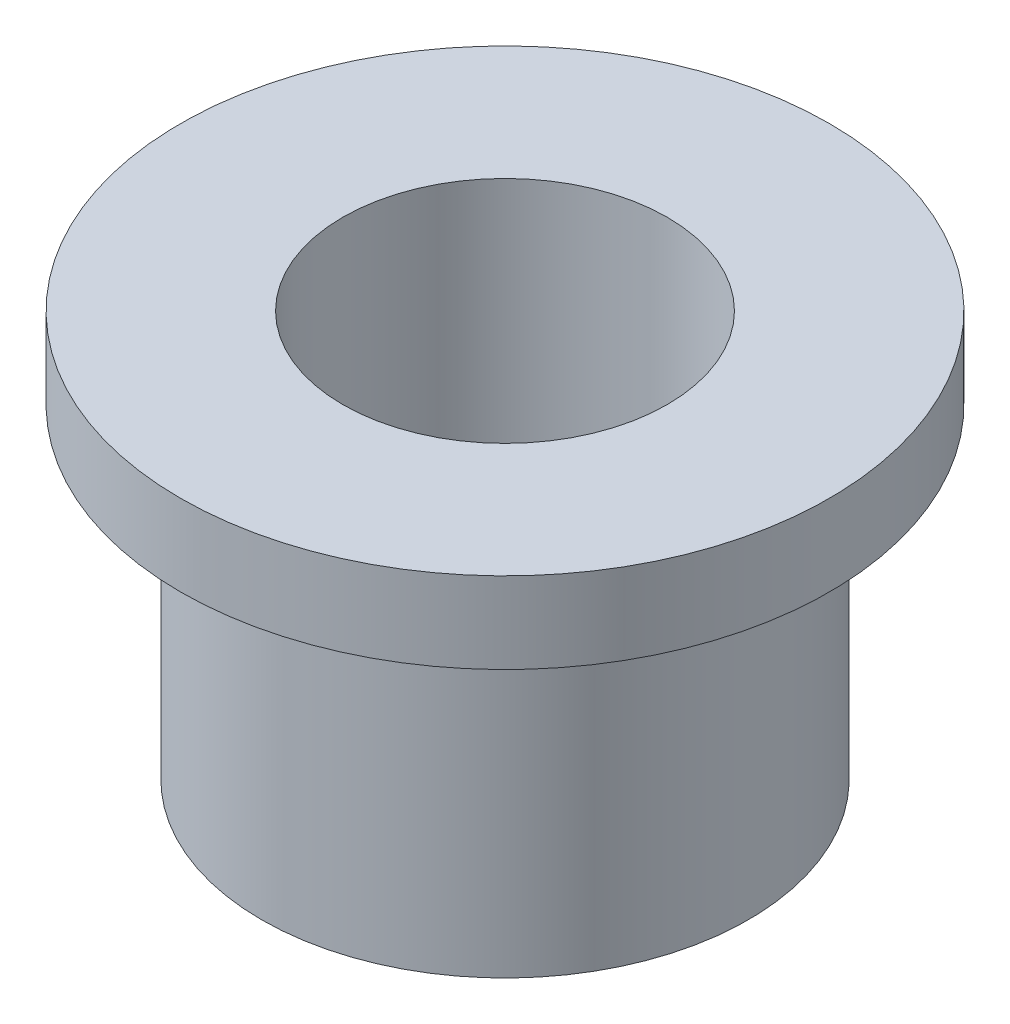
from build123d import *

# Parameters (mm, degrees)
SKETCH1_R           = 4.7625
SKETCH1_R_2         = 3.175
BOSS_EXTRUDE1_DEPTH = 6.35
SKETCH2_R           = 6.35
SKETCH2_R_2         = 3.175
BOSS_EXTRUDE2_DEPTH = 1.5875


with BuildPart() as part:
    # Sketch1 → Boss-Extrude1 (new body)
    with BuildSketch(Plane(origin=(0, 0, 0), x_dir=(1, 0, 0), z_dir=(0, 1, 0))):
        Circle(SKETCH1_R)
        Circle(SKETCH1_R_2, mode=Mode.SUBTRACT)
    extrude(amount=BOSS_EXTRUDE1_DEPTH)

    # Sketch2 → Boss-Extrude2 (add)
    with BuildSketch(Plane(origin=(0, 6.35, 0), x_dir=(1, 0, 0), z_dir=(0, 1, 0))):
        Circle(SKETCH2_R)
        Circle(SKETCH2_R_2, mode=Mode.SUBTRACT)
    extrude(amount=BOSS_EXTRUDE2_DEPTH)


solid = part.part
